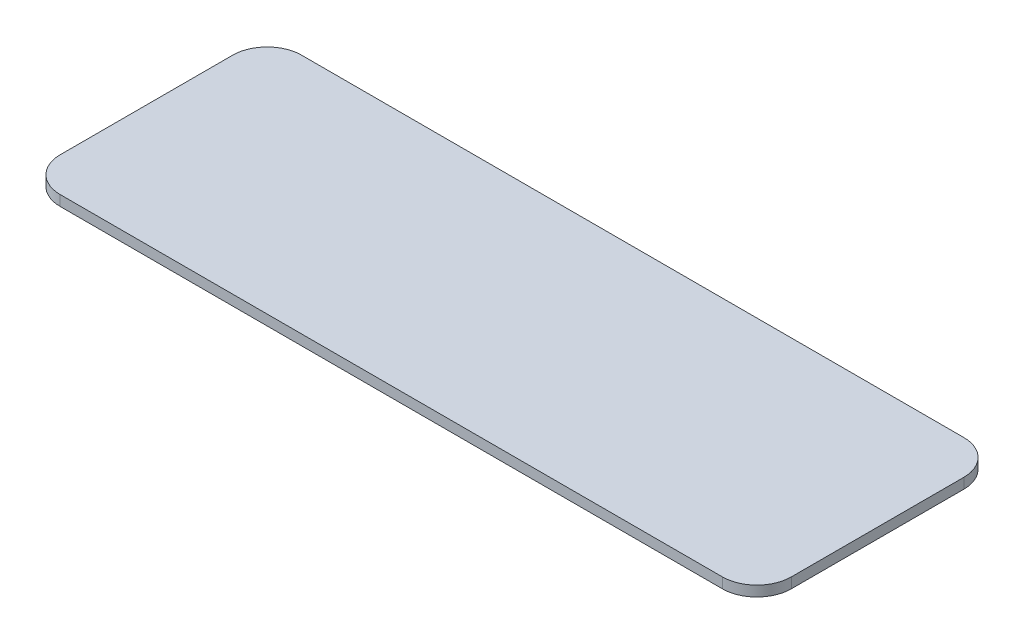
from build123d import *

# Parameters (mm, degrees)
SKETCH1_W           = 212
SKETCH1_H           = 70
BOSS_EXTRUDE1_DEPTH = 3
FILLET1_R           = 10


with BuildPart() as part:
    # Sketch1 → Boss-Extrude1 (new body)
    with BuildSketch(Plane(origin=(0, 0, 0), x_dir=(1, 0, 0), z_dir=(0, 1, 0))):
        Rectangle(SKETCH1_W, SKETCH1_H)
    extrude(amount=BOSS_EXTRUDE1_DEPTH)

    # Fillet1
    fillet1_edges = [part.edges().sort_by_distance(p)[0] for p in [
        (106, 1.5, 35),
        (-106, 1.5, 35),
        (-106, 1.5, -35),
        (106, 1.5, -35),
    ]]
    fillet(fillet1_edges, radius=FILLET1_R)


solid = part.part
